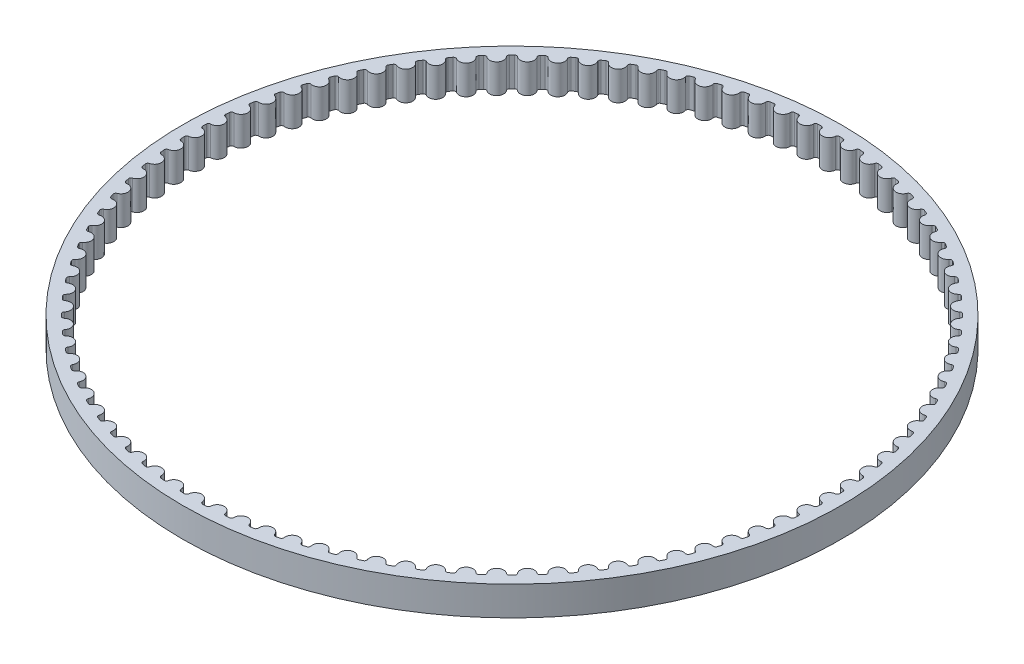
from build123d import *

# Parameters (mm, degrees)
SKETCH1_R           = 45.045764293
BOSS_EXTRUDE1_DEPTH = 4


with BuildPart() as part:
    # Sketch1 → Boss-Extrude1 (new body)
    with BuildSketch(Plane(origin=(0, 0, 0), x_dir=(1, 0, 0), z_dir=(0, 1, 0))):
        Circle(SKETCH1_R)
        with BuildLine():
            ThreePointArc((-1.725557121, -43.511562147), (-1.486700737, -43.520378087), (-1.247799561, -43.527882836))
            ThreePointArc((-1.247799561, -43.527882836), (-1.042007938, -43.453736054), (-0.941771649, -43.25931223))
            ThreePointArc((-0.941771649, -43.25931223), (0, -42.408617244), (0.941771649, -43.25931223))
            ThreePointArc((0.941771649, -43.25931223), (1.042007938, -43.453736054), (1.247799561, -43.527882836))
            ThreePointArc((1.247799561, -43.527882836), (1.486700737, -43.520378087), (1.725557121, -43.511562147))
            ThreePointArc((1.725557121, -43.511562147), (1.925809041, -43.423544502), (2.012543705, -43.222733559))
            ThreePointArc((2.012543705, -43.222733559), (2.894066388, -42.309752968), (3.891696029, -43.094196018))
            ThreePointArc((3.891696029, -43.094196018), (4.004966595, -43.281326229), (4.215338425, -43.341256441))
            ThreePointArc((4.215338425, -43.341256441), (4.453170525, -43.317465994), (4.69086846, -43.292370471))
            ThreePointArc((4.69086846, -43.292370471), (4.884647009, -43.190892341), (4.957475652, -42.984630551))
            ThreePointArc((4.957475652, -42.984630551), (5.774639303, -42.013621094), (6.823475525, -42.728154772))
            ThreePointArc((6.823475525, -42.728154772), (6.949252249, -42.907118882), (7.163223436, -42.952553101))
            ThreePointArc((7.163223436, -42.952553101), (7.398877577, -42.912587879), (7.634308804, -42.871329779))
            ThreePointArc((7.634308804, -42.871329779), (7.820710498, -42.756864302), (7.879293558, -42.546113353))
            ThreePointArc((7.879293558, -42.546113353), (8.628288183, -41.521602324), (9.723440829, -42.162895144))
            ThreePointArc((9.723440829, -42.162895144), (9.861137282, -42.33285874), (10.077710193, -42.363585131))
            ThreePointArc((10.077710193, -42.363585131), (10.310087647, -42.30763147), (10.542154476, -42.250403157))
            ThreePointArc((10.542154476, -42.250403157), (10.720310225, -42.123484024), (10.764374561, -41.909226535))
            ThreePointArc((10.764374561, -41.909226535), (11.441708002, -40.835990676), (12.578070964, -41.401052635))
            ThreePointArc((12.578070964, -41.401052635), (12.72704514, -41.561223269), (12.945210013, -41.577098571))
            ThreePointArc((12.945210013, -41.577098571), (13.173227328, -41.505417353), (13.400847758, -41.432485652))
            ThreePointArc((13.400847758, -41.432485652), (13.569926916, -41.293704618), (13.59926708, -41.076939557))
            ThreePointArc((13.59926708, -41.076939557), (14.201781295, -39.95998279), (15.374056325, -40.446179308))
            ThreePointArc((15.374056325, -40.446179308), (15.533613638, -40.59581019), (15.752353287, -40.596760386))
            ThreePointArc((15.752353287, -40.596760386), (15.974947342, -40.509685821), (16.197060101, -40.421390772))
            ThreePointArc((16.197060101, -40.421390772), (16.356274344, -40.2713949), (16.370753539, -40.053132924))
            ThreePointArc((16.370753539, -40.053132924), (16.895639329, -38.897663017), (18.098360738, -39.302727221))
            ThreePointArc((18.098360738, -39.302727221), (18.267757259, -39.441120703), (18.48605182, -39.427141362))
            ThreePointArc((18.48605182, -39.427141362), (18.702184778, -39.325079433), (18.917754273, -39.22183271))
            ThreePointArc((18.917754273, -39.22183271), (19.066361271, -39.061321348), (19.065911987, -38.842580096))
            ThreePointArc((19.065911987, -38.842580096), (19.510722092, -37.653984383), (20.738282239, -37.976027678))
            ThreePointArc((20.738282239, -37.976027678), (20.916728163, -38.102538505), (21.133559845, -38.073694806))
            ThreePointArc((21.133559845, -38.073694806), (21.342223995, -37.957121372), (21.550245143, -37.839404358))
            ThreePointArc((21.550245143, -37.839404358), (21.687552021, -37.669125885), (21.672176353, -37.45092523))
            ThreePointArc((21.672176353, -37.45092523), (22.034836863, -36.234745493), (23.281512296, -36.472266363))
            ThreePointArc((23.281512296, -36.472266363), (23.468175625, -36.586304684), (23.682533458, -36.542731109))
            ThreePointArc((23.682533458, -36.542731109), (23.882755912, -36.412189689), (24.082258821, -36.280551236))
            ThreePointArc((24.082258821, -36.280551236), (24.207625391, -36.101299569), (24.177395028, -35.884656862))
            ThreePointArc((24.177395028, -35.884656862), (24.456215052, -34.646563492), (25.716193194, -34.798454506))
            ThreePointArc((25.716193194, -34.798454506), (25.910203619, -34.899488621), (26.121088168, -34.84138833))
            ThreePointArc((26.121088168, -34.84138833), (26.311935396, -34.697487569), (26.501989892, -34.552541436))
            ThreePointArc((26.501989892, -34.552541436), (26.614831637, -34.365152328), (26.569887527, -34.151077659))
            ThreePointArc((26.569887527, -34.151077659), (26.763567078, -32.896843219), (28.030973329, -32.962396191))
            ThreePointArc((28.030973329, -32.962396191), (28.231426282, -33.049955033), (28.437854308, -32.977598916))
            ThreePointArc((28.437854308, -32.977598916), (28.618436491, -32.821009746), (28.798156452, -32.663431738))
            ThreePointArc((28.798156452, -32.663431738), (28.897947252, -32.468778884), (28.838498945, -32.258270367))
            ThreePointArc((28.838498945, -32.258270367), (28.946134999, -30.993742677), (30.215060127, -30.972651969))
            ThreePointArc((30.215060127, -30.972651969), (30.421021005, -31.046327297), (30.622030042, -30.960052713))
            ThreePointArc((30.622030042, -30.960052713), (30.791505224, -30.791505224), (30.960052713, -30.622030042))
            ThreePointArc((30.960052713, -30.622030042), (31.046327297, -30.421021005), (30.972651969, -30.215060127))
            ThreePointArc((30.972651969, -30.215060127), (30.993742677, -28.946134999), (32.258270367, -28.838498945))
            ThreePointArc((32.258270367, -28.838498945), (32.468778884, -28.897947252), (32.663431738, -28.798156452))
            ThreePointArc((32.663431738, -28.798156452), (32.821009746, -28.618436491), (32.977598916, -28.437854308))
            ThreePointArc((32.977598916, -28.437854308), (33.049955033, -28.231426282), (32.962396191, -28.030973329))
            ThreePointArc((32.962396191, -28.030973329), (32.896843219, -26.763567078), (34.151077659, -26.569887527))
            ThreePointArc((34.151077659, -26.569887527), (34.365152328, -26.614831637), (34.552541436, -26.501989892))
            ThreePointArc((34.552541436, -26.501989892), (34.697487569, -26.311935396), (34.84138833, -26.121088168))
            ThreePointArc((34.84138833, -26.121088168), (34.899488621, -25.910203619), (34.798454506, -25.716193194))
            ThreePointArc((34.798454506, -25.716193194), (34.646563492, -24.456215052), (35.884656862, -24.177395028))
            ThreePointArc((35.884656862, -24.177395028), (36.101299569, -24.207625391), (36.280551236, -24.082258821))
            ThreePointArc((36.280551236, -24.082258821), (36.412189689, -23.882755912), (36.542731109, -23.682533458))
            ThreePointArc((36.542731109, -23.682533458), (36.586304684, -23.468175625), (36.472266363, -23.281512296))
            ThreePointArc((36.472266363, -23.281512296), (36.234745493, -22.034836863), (37.45092523, -21.672176353))
            ThreePointArc((37.45092523, -21.672176353), (37.669125885, -21.687552021), (37.839404358, -21.550245143))
            ThreePointArc((37.839404358, -21.550245143), (37.957121372, -21.342223995), (38.073694806, -21.133559845))
            ThreePointArc((38.073694806, -21.133559845), (38.102538505, -20.916728163), (37.976027678, -20.738282239))
            ThreePointArc((37.976027678, -20.738282239), (37.653984383, -19.510722092), (38.842580096, -19.065911987))
            ThreePointArc((38.842580096, -19.065911987), (39.061321348, -19.066361271), (39.22183271, -18.917754273))
            ThreePointArc((39.22183271, -18.917754273), (39.325079433, -18.702184778), (39.427141362, -18.48605182))
            ThreePointArc((39.427141362, -18.48605182), (39.441120703, -18.267757259), (39.302727221, -18.098360738))
            ThreePointArc((39.302727221, -18.098360738), (38.897663017, -16.895639329), (40.053132924, -16.370753539))
            ThreePointArc((40.053132924, -16.370753539), (40.2713949, -16.356274344), (40.421390772, -16.197060101))
            ThreePointArc((40.421390772, -16.197060101), (40.509685821, -15.974947342), (40.596760386, -15.752353287))
            ThreePointArc((40.596760386, -15.752353287), (40.59581019, -15.533613638), (40.446179308, -15.374056325))
            ThreePointArc((40.446179308, -15.374056325), (39.95998279, -14.201781295), (41.076939557, -13.59926708))
            ThreePointArc((41.076939557, -13.59926708), (41.293704618, -13.569926916), (41.432485652, -13.400847758))
            ThreePointArc((41.432485652, -13.400847758), (41.505417353, -13.173227328), (41.577098571, -12.945210013))
            ThreePointArc((41.577098571, -12.945210013), (41.561223269, -12.72704514), (41.401052635, -12.578070964))
            ThreePointArc((41.401052635, -12.578070964), (40.835990676, -11.441708002), (41.909226535, -10.764374561))
            ThreePointArc((41.909226535, -10.764374561), (42.123484024, -10.720310225), (42.250403157, -10.542154476))
            ThreePointArc((42.250403157, -10.542154476), (42.30763147, -10.310087647), (42.363585131, -10.077710193))
            ThreePointArc((42.363585131, -10.077710193), (42.33285874, -9.861137282), (42.162895144, -9.723440829))
            ThreePointArc((42.162895144, -9.723440829), (41.521602324, -8.628288183), (42.546113353, -7.879293558))
            ThreePointArc((42.546113353, -7.879293558), (42.756864302, -7.820710498), (42.871329779, -7.634308804))
            ThreePointArc((42.871329779, -7.634308804), (42.912587879, -7.398877577), (42.952553101, -7.163223436))
            ThreePointArc((42.952553101, -7.163223436), (42.907118882, -6.949252249), (42.728154772, -6.823475525))
            ThreePointArc((42.728154772, -6.823475525), (42.013621094, -5.774639303), (42.984630551, -4.957475652))
            ThreePointArc((42.984630551, -4.957475652), (43.190892341, -4.884647009), (43.292370471, -4.69086846))
            ThreePointArc((43.292370471, -4.69086846), (43.317465994, -4.453170525), (43.341256441, -4.215338425))
            ThreePointArc((43.341256441, -4.215338425), (43.281326229, -4.004966595), (43.094196018, -3.891696029))
            ThreePointArc((43.094196018, -3.891696029), (42.309752968, -2.894066388), (43.222733559, -2.012543705))
            ThreePointArc((43.222733559, -2.012543705), (43.423544502, -1.925809041), (43.511562147, -1.725557121))
            ThreePointArc((43.511562147, -1.725557121), (43.520378087, -1.486700737), (43.527882836, -1.247799561))
            ThreePointArc((43.527882836, -1.247799561), (43.453736054, -1.042007938), (43.25931223, -0.941771649))
            ThreePointArc((43.25931223, -0.941771649), (42.408617244, 0), (43.25931223, 0.941771649))
            ThreePointArc((43.25931223, 0.941771649), (43.453736054, 1.042007938), (43.527882836, 1.247799561))
            ThreePointArc((43.527882836, 1.247799561), (43.520378087, 1.486700737), (43.511562147, 1.725557121))
            ThreePointArc((43.511562147, 1.725557121), (43.423544502, 1.925809041), (43.222733559, 2.012543705))
            ThreePointArc((43.222733559, 2.012543705), (42.309752968, 2.894066388), (43.094196018, 3.891696029))
            ThreePointArc((43.094196018, 3.891696029), (43.281326229, 4.004966595), (43.341256441, 4.215338425))
            ThreePointArc((43.341256441, 4.215338425), (43.317465994, 4.453170525), (43.292370471, 4.69086846))
            ThreePointArc((43.292370471, 4.69086846), (43.190892341, 4.884647009), (42.984630551, 4.957475652))
            ThreePointArc((42.984630551, 4.957475652), (42.013621094, 5.774639303), (42.728154772, 6.823475525))
            ThreePointArc((42.728154772, 6.823475525), (42.907118882, 6.949252249), (42.952553101, 7.163223436))
            ThreePointArc((42.952553101, 7.163223436), (42.912587879, 7.398877577), (42.871329779, 7.634308804))
            ThreePointArc((42.871329779, 7.634308804), (42.756864302, 7.820710498), (42.546113353, 7.879293558))
            ThreePointArc((42.546113353, 7.879293558), (41.521602324, 8.628288183), (42.162895144, 9.723440829))
            ThreePointArc((42.162895144, 9.723440829), (42.33285874, 9.861137282), (42.363585131, 10.077710193))
            ThreePointArc((42.363585131, 10.077710193), (42.30763147, 10.310087647), (42.250403157, 10.542154476))
            ThreePointArc((42.250403157, 10.542154476), (42.123484024, 10.720310225), (41.909226535, 10.764374561))
            ThreePointArc((41.909226535, 10.764374561), (40.835990676, 11.441708002), (41.401052635, 12.578070964))
            ThreePointArc((41.401052635, 12.578070964), (41.561223269, 12.72704514), (41.577098571, 12.945210013))
            ThreePointArc((41.577098571, 12.945210013), (41.505417353, 13.173227328), (41.432485652, 13.400847758))
            ThreePointArc((41.432485652, 13.400847758), (41.293704618, 13.569926916), (41.076939557, 13.59926708))
            ThreePointArc((41.076939557, 13.59926708), (39.95998279, 14.201781295), (40.446179308, 15.374056325))
            ThreePointArc((40.446179308, 15.374056325), (40.59581019, 15.533613638), (40.596760386, 15.752353287))
            ThreePointArc((40.596760386, 15.752353287), (40.509685821, 15.974947342), (40.421390772, 16.197060101))
            ThreePointArc((40.421390772, 16.197060101), (40.2713949, 16.356274344), (40.053132924, 16.370753539))
            ThreePointArc((40.053132924, 16.370753539), (38.897663017, 16.895639329), (39.302727221, 18.098360738))
            ThreePointArc((39.302727221, 18.098360738), (39.441120703, 18.267757259), (39.427141362, 18.48605182))
            ThreePointArc((39.427141362, 18.48605182), (39.325079433, 18.702184778), (39.22183271, 18.917754273))
            ThreePointArc((39.22183271, 18.917754273), (39.061321348, 19.066361271), (38.842580096, 19.065911987))
            ThreePointArc((38.842580096, 19.065911987), (37.653984383, 19.510722092), (37.976027678, 20.738282239))
            ThreePointArc((37.976027678, 20.738282239), (38.102538505, 20.916728163), (38.073694806, 21.133559845))
            ThreePointArc((38.073694806, 21.133559845), (37.957121372, 21.342223995), (37.839404358, 21.550245143))
            ThreePointArc((37.839404358, 21.550245143), (37.669125885, 21.687552021), (37.45092523, 21.672176353))
            ThreePointArc((37.45092523, 21.672176353), (36.234745493, 22.034836863), (36.472266363, 23.281512296))
            ThreePointArc((36.472266363, 23.281512296), (36.586304684, 23.468175625), (36.542731109, 23.682533458))
            ThreePointArc((36.542731109, 23.682533458), (36.412189689, 23.882755912), (36.280551236, 24.082258821))
            ThreePointArc((36.280551236, 24.082258821), (36.101299569, 24.207625391), (35.884656862, 24.177395028))
            ThreePointArc((35.884656862, 24.177395028), (34.646563492, 24.456215052), (34.798454506, 25.716193194))
            ThreePointArc((34.798454506, 25.716193194), (34.899488621, 25.910203619), (34.84138833, 26.121088168))
            ThreePointArc((34.84138833, 26.121088168), (34.697487569, 26.311935396), (34.552541436, 26.501989892))
            ThreePointArc((34.552541436, 26.501989892), (34.365152328, 26.614831637), (34.151077659, 26.569887527))
            ThreePointArc((34.151077659, 26.569887527), (32.896843219, 26.763567078), (32.962396191, 28.030973329))
            ThreePointArc((32.962396191, 28.030973329), (33.049955033, 28.231426282), (32.977598916, 28.437854308))
            ThreePointArc((32.977598916, 28.437854308), (32.821009746, 28.618436491), (32.663431738, 28.798156452))
            ThreePointArc((32.663431738, 28.798156452), (32.468778884, 28.897947252), (32.258270367, 28.838498945))
            ThreePointArc((32.258270367, 28.838498945), (30.993742677, 28.946134999), (30.972651969, 30.215060127))
            ThreePointArc((30.972651969, 30.215060127), (31.046327297, 30.421021005), (30.960052713, 30.622030042))
            ThreePointArc((30.960052713, 30.622030042), (30.791505224, 30.791505224), (30.622030042, 30.960052713))
            ThreePointArc((30.622030042, 30.960052713), (30.421021005, 31.046327297), (30.215060127, 30.972651969))
            ThreePointArc((30.215060127, 30.972651969), (28.946134999, 30.993742677), (28.838498945, 32.258270367))
            ThreePointArc((28.838498945, 32.258270367), (28.897947252, 32.468778884), (28.798156452, 32.663431738))
            ThreePointArc((28.798156452, 32.663431738), (28.618436491, 32.821009746), (28.437854308, 32.977598916))
            ThreePointArc((28.437854308, 32.977598916), (28.231426282, 33.049955033), (28.030973329, 32.962396191))
            ThreePointArc((28.030973329, 32.962396191), (26.763567078, 32.896843219), (26.569887527, 34.151077659))
            ThreePointArc((26.569887527, 34.151077659), (26.614831637, 34.365152328), (26.501989892, 34.552541436))
            ThreePointArc((26.501989892, 34.552541436), (26.311935396, 34.697487569), (26.121088168, 34.84138833))
            ThreePointArc((26.121088168, 34.84138833), (25.910203619, 34.899488621), (25.716193194, 34.798454506))
            ThreePointArc((25.716193194, 34.798454506), (24.456215052, 34.646563492), (24.177395028, 35.884656862))
            ThreePointArc((24.177395028, 35.884656862), (24.207625391, 36.101299569), (24.082258821, 36.280551236))
            ThreePointArc((24.082258821, 36.280551236), (23.882755912, 36.412189689), (23.682533458, 36.542731109))
            ThreePointArc((23.682533458, 36.542731109), (23.468175625, 36.586304684), (23.281512296, 36.472266363))
            ThreePointArc((23.281512296, 36.472266363), (22.034836863, 36.234745493), (21.672176353, 37.45092523))
            ThreePointArc((21.672176353, 37.45092523), (21.687552021, 37.669125885), (21.550245143, 37.839404358))
            ThreePointArc((21.550245143, 37.839404358), (21.342223995, 37.957121372), (21.133559845, 38.073694806))
            ThreePointArc((21.133559845, 38.073694806), (20.916728163, 38.102538505), (20.738282239, 37.976027678))
            ThreePointArc((20.738282239, 37.976027678), (19.510722092, 37.653984383), (19.065911987, 38.842580096))
            ThreePointArc((19.065911987, 38.842580096), (19.066361271, 39.061321348), (18.917754273, 39.22183271))
            ThreePointArc((18.917754273, 39.22183271), (18.702184778, 39.325079433), (18.48605182, 39.427141362))
            ThreePointArc((18.48605182, 39.427141362), (18.267757259, 39.441120703), (18.098360738, 39.302727221))
            ThreePointArc((18.098360738, 39.302727221), (16.895639329, 38.897663017), (16.370753539, 40.053132924))
            ThreePointArc((16.370753539, 40.053132924), (16.356274344, 40.2713949), (16.197060101, 40.421390772))
            ThreePointArc((16.197060101, 40.421390772), (15.974947342, 40.509685821), (15.752353287, 40.596760386))
            ThreePointArc((15.752353287, 40.596760386), (15.533613638, 40.59581019), (15.374056325, 40.446179308))
            ThreePointArc((15.374056325, 40.446179308), (14.201781295, 39.95998279), (13.59926708, 41.076939557))
            ThreePointArc((13.59926708, 41.076939557), (13.569926916, 41.293704618), (13.400847758, 41.432485652))
            ThreePointArc((13.400847758, 41.432485652), (13.173227328, 41.505417353), (12.945210013, 41.577098571))
            ThreePointArc((12.945210013, 41.577098571), (12.72704514, 41.561223269), (12.578070964, 41.401052635))
            ThreePointArc((12.578070964, 41.401052635), (11.441708002, 40.835990676), (10.764374561, 41.909226535))
            ThreePointArc((10.764374561, 41.909226535), (10.720310225, 42.123484024), (10.542154476, 42.250403157))
            ThreePointArc((10.542154476, 42.250403157), (10.310087647, 42.30763147), (10.077710193, 42.363585131))
            ThreePointArc((10.077710193, 42.363585131), (9.861137282, 42.33285874), (9.723440829, 42.162895144))
            ThreePointArc((9.723440829, 42.162895144), (8.628288183, 41.521602324), (7.879293558, 42.546113353))
            ThreePointArc((7.879293558, 42.546113353), (7.820710498, 42.756864302), (7.634308804, 42.871329779))
            ThreePointArc((7.634308804, 42.871329779), (7.398877577, 42.912587879), (7.163223436, 42.952553101))
            ThreePointArc((7.163223436, 42.952553101), (6.949252249, 42.907118882), (6.823475525, 42.728154772))
            ThreePointArc((6.823475525, 42.728154772), (5.774639303, 42.013621094), (4.957475652, 42.984630551))
            ThreePointArc((4.957475652, 42.984630551), (4.884647009, 43.190892341), (4.69086846, 43.292370471))
            ThreePointArc((4.69086846, 43.292370471), (4.453170525, 43.317465994), (4.215338425, 43.341256441))
            ThreePointArc((4.215338425, 43.341256441), (4.004966595, 43.281326229), (3.891696029, 43.094196018))
            ThreePointArc((3.891696029, 43.094196018), (2.894066388, 42.309752968), (2.012543705, 43.222733559))
            ThreePointArc((2.012543705, 43.222733559), (1.925809041, 43.423544502), (1.725557121, 43.511562147))
            ThreePointArc((1.725557121, 43.511562147), (1.486700737, 43.520378087), (1.247799561, 43.527882836))
            ThreePointArc((1.247799561, 43.527882836), (1.042007938, 43.453736054), (0.941771649, 43.25931223))
            ThreePointArc((0.941771649, 43.25931223), (0, 42.408617244), (-0.941771649, 43.25931223))
            ThreePointArc((-0.941771649, 43.25931223), (-1.042007938, 43.453736054), (-1.247799561, 43.527882836))
            ThreePointArc((-1.247799561, 43.527882836), (-1.486700737, 43.520378087), (-1.725557121, 43.511562147))
            ThreePointArc((-1.725557121, 43.511562147), (-1.925809041, 43.423544502), (-2.012543705, 43.222733559))
            ThreePointArc((-2.012543705, 43.222733559), (-2.894066388, 42.309752968), (-3.891696029, 43.094196018))
            ThreePointArc((-3.891696029, 43.094196018), (-4.004966595, 43.281326229), (-4.215338425, 43.341256441))
            ThreePointArc((-4.215338425, 43.341256441), (-4.453170525, 43.317465994), (-4.69086846, 43.292370471))
            ThreePointArc((-4.69086846, 43.292370471), (-4.884647009, 43.190892341), (-4.957475652, 42.984630551))
            ThreePointArc((-4.957475652, 42.984630551), (-5.774639303, 42.013621094), (-6.823475525, 42.728154772))
            ThreePointArc((-6.823475525, 42.728154772), (-6.949252249, 42.907118882), (-7.163223436, 42.952553101))
            ThreePointArc((-7.163223436, 42.952553101), (-7.398877577, 42.912587879), (-7.634308804, 42.871329779))
            ThreePointArc((-7.634308804, 42.871329779), (-7.820710498, 42.756864302), (-7.879293558, 42.546113353))
            ThreePointArc((-7.879293558, 42.546113353), (-8.628288183, 41.521602324), (-9.723440829, 42.162895144))
            ThreePointArc((-9.723440829, 42.162895144), (-9.861137282, 42.33285874), (-10.077710193, 42.363585131))
            ThreePointArc((-10.077710193, 42.363585131), (-10.310087647, 42.30763147), (-10.542154476, 42.250403157))
            ThreePointArc((-10.542154476, 42.250403157), (-10.720310225, 42.123484024), (-10.764374561, 41.909226535))
            ThreePointArc((-10.764374561, 41.909226535), (-11.441708002, 40.835990676), (-12.578070964, 41.401052635))
            ThreePointArc((-12.578070964, 41.401052635), (-12.72704514, 41.561223269), (-12.945210013, 41.577098571))
            ThreePointArc((-12.945210013, 41.577098571), (-13.173227328, 41.505417353), (-13.400847758, 41.432485652))
            ThreePointArc((-13.400847758, 41.432485652), (-13.569926916, 41.293704618), (-13.59926708, 41.076939557))
            ThreePointArc((-13.59926708, 41.076939557), (-14.201781295, 39.95998279), (-15.374056325, 40.446179308))
            ThreePointArc((-15.374056325, 40.446179308), (-15.533613638, 40.59581019), (-15.752353287, 40.596760386))
            ThreePointArc((-15.752353287, 40.596760386), (-15.974947342, 40.509685821), (-16.197060101, 40.421390772))
            ThreePointArc((-16.197060101, 40.421390772), (-16.356274344, 40.2713949), (-16.370753539, 40.053132924))
            ThreePointArc((-16.370753539, 40.053132924), (-16.895639329, 38.897663017), (-18.098360738, 39.302727221))
            ThreePointArc((-18.098360738, 39.302727221), (-18.267757259, 39.441120703), (-18.48605182, 39.427141362))
            ThreePointArc((-18.48605182, 39.427141362), (-18.702184778, 39.325079433), (-18.917754273, 39.22183271))
            ThreePointArc((-18.917754273, 39.22183271), (-19.066361271, 39.061321348), (-19.065911987, 38.842580096))
            ThreePointArc((-19.065911987, 38.842580096), (-19.510722092, 37.653984383), (-20.738282239, 37.976027678))
            ThreePointArc((-20.738282239, 37.976027678), (-20.916728163, 38.102538505), (-21.133559845, 38.073694806))
            ThreePointArc((-21.133559845, 38.073694806), (-21.342223995, 37.957121372), (-21.550245143, 37.839404358))
            ThreePointArc((-21.550245143, 37.839404358), (-21.687552021, 37.669125885), (-21.672176353, 37.45092523))
            ThreePointArc((-21.672176353, 37.45092523), (-22.034836863, 36.234745493), (-23.281512296, 36.472266363))
            ThreePointArc((-23.281512296, 36.472266363), (-23.468175625, 36.586304684), (-23.682533458, 36.542731109))
            ThreePointArc((-23.682533458, 36.542731109), (-23.882755912, 36.412189689), (-24.082258821, 36.280551236))
            ThreePointArc((-24.082258821, 36.280551236), (-24.207625391, 36.101299569), (-24.177395028, 35.884656862))
            ThreePointArc((-24.177395028, 35.884656862), (-24.456215052, 34.646563492), (-25.716193194, 34.798454506))
            ThreePointArc((-25.716193194, 34.798454506), (-25.910203619, 34.899488621), (-26.121088168, 34.84138833))
            ThreePointArc((-26.121088168, 34.84138833), (-26.311935396, 34.697487569), (-26.501989892, 34.552541436))
            ThreePointArc((-26.501989892, 34.552541436), (-26.614831637, 34.365152328), (-26.569887527, 34.151077659))
            ThreePointArc((-26.569887527, 34.151077659), (-26.763567078, 32.896843219), (-28.030973329, 32.962396191))
            ThreePointArc((-28.030973329, 32.962396191), (-28.231426282, 33.049955033), (-28.437854308, 32.977598916))
            ThreePointArc((-28.437854308, 32.977598916), (-28.618436491, 32.821009746), (-28.798156452, 32.663431738))
            ThreePointArc((-28.798156452, 32.663431738), (-28.897947252, 32.468778884), (-28.838498945, 32.258270367))
            ThreePointArc((-28.838498945, 32.258270367), (-28.946134999, 30.993742677), (-30.215060127, 30.972651969))
            ThreePointArc((-30.215060127, 30.972651969), (-30.421021005, 31.046327297), (-30.622030042, 30.960052713))
            ThreePointArc((-30.622030042, 30.960052713), (-30.791505224, 30.791505224), (-30.960052713, 30.622030042))
            ThreePointArc((-30.960052713, 30.622030042), (-31.046327297, 30.421021005), (-30.972651969, 30.215060127))
            ThreePointArc((-30.972651969, 30.215060127), (-30.993742677, 28.946134999), (-32.258270367, 28.838498945))
            ThreePointArc((-32.258270367, 28.838498945), (-32.468778884, 28.897947252), (-32.663431738, 28.798156452))
            ThreePointArc((-32.663431738, 28.798156452), (-32.821009746, 28.618436491), (-32.977598916, 28.437854308))
            ThreePointArc((-32.977598916, 28.437854308), (-33.049955033, 28.231426282), (-32.962396191, 28.030973329))
            ThreePointArc((-32.962396191, 28.030973329), (-32.896843219, 26.763567078), (-34.151077659, 26.569887527))
            ThreePointArc((-34.151077659, 26.569887527), (-34.365152328, 26.614831637), (-34.552541436, 26.501989892))
            ThreePointArc((-34.552541436, 26.501989892), (-34.697487569, 26.311935396), (-34.84138833, 26.121088168))
            ThreePointArc((-34.84138833, 26.121088168), (-34.899488621, 25.910203619), (-34.798454506, 25.716193194))
            ThreePointArc((-34.798454506, 25.716193194), (-34.646563492, 24.456215052), (-35.884656862, 24.177395028))
            ThreePointArc((-35.884656862, 24.177395028), (-36.101299569, 24.207625391), (-36.280551236, 24.082258821))
            ThreePointArc((-36.280551236, 24.082258821), (-36.412189689, 23.882755912), (-36.542731109, 23.682533458))
            ThreePointArc((-36.542731109, 23.682533458), (-36.586304684, 23.468175625), (-36.472266363, 23.281512296))
            ThreePointArc((-36.472266363, 23.281512296), (-36.234745493, 22.034836863), (-37.45092523, 21.672176353))
            ThreePointArc((-37.45092523, 21.672176353), (-37.669125885, 21.687552021), (-37.839404358, 21.550245143))
            ThreePointArc((-37.839404358, 21.550245143), (-37.957121372, 21.342223995), (-38.073694806, 21.133559845))
            ThreePointArc((-38.073694806, 21.133559845), (-38.102538505, 20.916728163), (-37.976027678, 20.738282239))
            ThreePointArc((-37.976027678, 20.738282239), (-37.653984383, 19.510722092), (-38.842580096, 19.065911987))
            ThreePointArc((-38.842580096, 19.065911987), (-39.061321348, 19.066361271), (-39.22183271, 18.917754273))
            ThreePointArc((-39.22183271, 18.917754273), (-39.325079433, 18.702184778), (-39.427141362, 18.48605182))
            ThreePointArc((-39.427141362, 18.48605182), (-39.441120703, 18.267757259), (-39.302727221, 18.098360738))
            ThreePointArc((-39.302727221, 18.098360738), (-38.897663017, 16.895639329), (-40.053132924, 16.370753539))
            ThreePointArc((-40.053132924, 16.370753539), (-40.2713949, 16.356274344), (-40.421390772, 16.197060101))
            ThreePointArc((-40.421390772, 16.197060101), (-40.509685821, 15.974947342), (-40.596760386, 15.752353287))
            ThreePointArc((-40.596760386, 15.752353287), (-40.59581019, 15.533613638), (-40.446179308, 15.374056325))
            ThreePointArc((-40.446179308, 15.374056325), (-39.95998279, 14.201781295), (-41.076939557, 13.59926708))
            ThreePointArc((-41.076939557, 13.59926708), (-41.293704618, 13.569926916), (-41.432485652, 13.400847758))
            ThreePointArc((-41.432485652, 13.400847758), (-41.505417353, 13.173227328), (-41.577098571, 12.945210013))
            ThreePointArc((-41.577098571, 12.945210013), (-41.561223269, 12.72704514), (-41.401052635, 12.578070964))
            ThreePointArc((-41.401052635, 12.578070964), (-40.835990676, 11.441708002), (-41.909226535, 10.764374561))
            ThreePointArc((-41.909226535, 10.764374561), (-42.123484024, 10.720310225), (-42.250403157, 10.542154476))
            ThreePointArc((-42.250403157, 10.542154476), (-42.30763147, 10.310087647), (-42.363585131, 10.077710193))
            ThreePointArc((-42.363585131, 10.077710193), (-42.33285874, 9.861137282), (-42.162895144, 9.723440829))
            ThreePointArc((-42.162895144, 9.723440829), (-41.521602324, 8.628288183), (-42.546113353, 7.879293558))
            ThreePointArc((-42.546113353, 7.879293558), (-42.756864302, 7.820710498), (-42.871329779, 7.634308804))
            ThreePointArc((-42.871329779, 7.634308804), (-42.912587879, 7.398877577), (-42.952553101, 7.163223436))
            ThreePointArc((-42.952553101, 7.163223436), (-42.907118882, 6.949252249), (-42.728154772, 6.823475525))
            ThreePointArc((-42.728154772, 6.823475525), (-42.013621094, 5.774639303), (-42.984630551, 4.957475652))
            ThreePointArc((-42.984630551, 4.957475652), (-43.190892341, 4.884647009), (-43.292370471, 4.69086846))
            ThreePointArc((-43.292370471, 4.69086846), (-43.317465994, 4.453170525), (-43.341256441, 4.215338425))
            ThreePointArc((-43.341256441, 4.215338425), (-43.281326229, 4.004966595), (-43.094196018, 3.891696029))
            ThreePointArc((-43.094196018, 3.891696029), (-42.309752968, 2.894066388), (-43.222733559, 2.012543705))
            ThreePointArc((-43.222733559, 2.012543705), (-43.423544502, 1.925809041), (-43.511562147, 1.725557121))
            ThreePointArc((-43.511562147, 1.725557121), (-43.520378087, 1.486700737), (-43.527882836, 1.247799561))
            ThreePointArc((-43.527882836, 1.247799561), (-43.453736054, 1.042007938), (-43.25931223, 0.941771649))
            ThreePointArc((-43.25931223, 0.941771649), (-42.408617244, 0), (-43.25931223, -0.941771649))
            ThreePointArc((-43.25931223, -0.941771649), (-43.453736054, -1.042007938), (-43.527882836, -1.247799561))
            ThreePointArc((-43.527882836, -1.247799561), (-43.520378087, -1.486700737), (-43.511562147, -1.725557121))
            ThreePointArc((-43.511562147, -1.725557121), (-43.423544502, -1.925809041), (-43.222733559, -2.012543705))
            ThreePointArc((-43.222733559, -2.012543705), (-42.309752968, -2.894066388), (-43.094196018, -3.891696029))
            ThreePointArc((-43.094196018, -3.891696029), (-43.281326229, -4.004966595), (-43.341256441, -4.215338425))
            ThreePointArc((-43.341256441, -4.215338425), (-43.317465994, -4.453170525), (-43.292370471, -4.69086846))
            ThreePointArc((-43.292370471, -4.69086846), (-43.190892341, -4.884647009), (-42.984630551, -4.957475652))
            ThreePointArc((-42.984630551, -4.957475652), (-42.013621094, -5.774639303), (-42.728154772, -6.823475525))
            ThreePointArc((-42.728154772, -6.823475525), (-42.907118882, -6.949252249), (-42.952553101, -7.163223436))
            ThreePointArc((-42.952553101, -7.163223436), (-42.912587879, -7.398877577), (-42.871329779, -7.634308804))
            ThreePointArc((-42.871329779, -7.634308804), (-42.756864302, -7.820710498), (-42.546113353, -7.879293558))
            ThreePointArc((-42.546113353, -7.879293558), (-41.521602324, -8.628288183), (-42.162895144, -9.723440829))
            ThreePointArc((-42.162895144, -9.723440829), (-42.33285874, -9.861137282), (-42.363585131, -10.077710193))
            ThreePointArc((-42.363585131, -10.077710193), (-42.30763147, -10.310087647), (-42.250403157, -10.542154476))
            ThreePointArc((-42.250403157, -10.542154476), (-42.123484024, -10.720310225), (-41.909226535, -10.764374561))
            ThreePointArc((-41.909226535, -10.764374561), (-40.835990676, -11.441708002), (-41.401052635, -12.578070964))
            ThreePointArc((-41.401052635, -12.578070964), (-41.561223269, -12.72704514), (-41.577098571, -12.945210013))
            ThreePointArc((-41.577098571, -12.945210013), (-41.505417353, -13.173227328), (-41.432485652, -13.400847758))
            ThreePointArc((-41.432485652, -13.400847758), (-41.293704618, -13.569926916), (-41.076939557, -13.59926708))
            ThreePointArc((-41.076939557, -13.59926708), (-39.95998279, -14.201781295), (-40.446179308, -15.374056325))
            ThreePointArc((-40.446179308, -15.374056325), (-40.59581019, -15.533613638), (-40.596760386, -15.752353287))
            ThreePointArc((-40.596760386, -15.752353287), (-40.509685821, -15.974947342), (-40.421390772, -16.197060101))
            ThreePointArc((-40.421390772, -16.197060101), (-40.2713949, -16.356274344), (-40.053132924, -16.370753539))
            ThreePointArc((-40.053132924, -16.370753539), (-38.897663017, -16.895639329), (-39.302727221, -18.098360738))
            ThreePointArc((-39.302727221, -18.098360738), (-39.441120703, -18.267757259), (-39.427141362, -18.48605182))
            ThreePointArc((-39.427141362, -18.48605182), (-39.325079433, -18.702184778), (-39.22183271, -18.917754273))
            ThreePointArc((-39.22183271, -18.917754273), (-39.061321348, -19.066361271), (-38.842580096, -19.065911987))
            ThreePointArc((-38.842580096, -19.065911987), (-37.653984383, -19.510722092), (-37.976027678, -20.738282239))
            ThreePointArc((-37.976027678, -20.738282239), (-38.102538505, -20.916728163), (-38.073694806, -21.133559845))
            ThreePointArc((-38.073694806, -21.133559845), (-37.957121372, -21.342223995), (-37.839404358, -21.550245143))
            ThreePointArc((-37.839404358, -21.550245143), (-37.669125885, -21.687552021), (-37.45092523, -21.672176353))
            ThreePointArc((-37.45092523, -21.672176353), (-36.234745493, -22.034836863), (-36.472266363, -23.281512296))
            ThreePointArc((-36.472266363, -23.281512296), (-36.586304684, -23.468175625), (-36.542731109, -23.682533458))
            ThreePointArc((-36.542731109, -23.682533458), (-36.412189689, -23.882755912), (-36.280551236, -24.082258821))
            ThreePointArc((-36.280551236, -24.082258821), (-36.101299569, -24.207625391), (-35.884656862, -24.177395028))
            ThreePointArc((-35.884656862, -24.177395028), (-34.646563492, -24.456215052), (-34.798454506, -25.716193194))
            ThreePointArc((-34.798454506, -25.716193194), (-34.899488621, -25.910203619), (-34.84138833, -26.121088168))
            ThreePointArc((-34.84138833, -26.121088168), (-34.697487569, -26.311935396), (-34.552541436, -26.501989892))
            ThreePointArc((-34.552541436, -26.501989892), (-34.365152328, -26.614831637), (-34.151077659, -26.569887527))
            ThreePointArc((-34.151077659, -26.569887527), (-32.896843219, -26.763567078), (-32.962396191, -28.030973329))
            ThreePointArc((-32.962396191, -28.030973329), (-33.049955033, -28.231426282), (-32.977598916, -28.437854308))
            ThreePointArc((-32.977598916, -28.437854308), (-32.821009746, -28.618436491), (-32.663431738, -28.798156452))
            ThreePointArc((-32.663431738, -28.798156452), (-32.468778884, -28.897947252), (-32.258270367, -28.838498945))
            ThreePointArc((-32.258270367, -28.838498945), (-30.993742677, -28.946134999), (-30.972651969, -30.215060127))
            ThreePointArc((-30.972651969, -30.215060127), (-31.046327297, -30.421021005), (-30.960052713, -30.622030042))
            ThreePointArc((-30.960052713, -30.622030042), (-30.791505224, -30.791505224), (-30.622030042, -30.960052713))
            ThreePointArc((-30.622030042, -30.960052713), (-30.421021005, -31.046327297), (-30.215060127, -30.972651969))
            ThreePointArc((-30.215060127, -30.972651969), (-28.946134999, -30.993742677), (-28.838498945, -32.258270367))
            ThreePointArc((-28.838498945, -32.258270367), (-28.897947252, -32.468778884), (-28.798156452, -32.663431738))
            ThreePointArc((-28.798156452, -32.663431738), (-28.618436491, -32.821009746), (-28.437854308, -32.977598916))
            ThreePointArc((-28.437854308, -32.977598916), (-28.231426282, -33.049955033), (-28.030973329, -32.962396191))
            ThreePointArc((-28.030973329, -32.962396191), (-26.763567078, -32.896843219), (-26.569887527, -34.151077659))
            ThreePointArc((-26.569887527, -34.151077659), (-26.614831637, -34.365152328), (-26.501989892, -34.552541436))
            ThreePointArc((-26.501989892, -34.552541436), (-26.311935396, -34.697487569), (-26.121088168, -34.84138833))
            ThreePointArc((-26.121088168, -34.84138833), (-25.910203619, -34.899488621), (-25.716193194, -34.798454506))
            ThreePointArc((-25.716193194, -34.798454506), (-24.456215052, -34.646563492), (-24.177395028, -35.884656862))
            ThreePointArc((-24.177395028, -35.884656862), (-24.207625391, -36.101299569), (-24.082258821, -36.280551236))
            ThreePointArc((-24.082258821, -36.280551236), (-23.882755912, -36.412189689), (-23.682533458, -36.542731109))
            ThreePointArc((-23.682533458, -36.542731109), (-23.468175625, -36.586304684), (-23.281512296, -36.472266363))
            ThreePointArc((-23.281512296, -36.472266363), (-22.034836863, -36.234745493), (-21.672176353, -37.45092523))
            ThreePointArc((-21.672176353, -37.45092523), (-21.687552021, -37.669125885), (-21.550245143, -37.839404358))
            ThreePointArc((-21.550245143, -37.839404358), (-21.342223995, -37.957121372), (-21.133559845, -38.073694806))
            ThreePointArc((-21.133559845, -38.073694806), (-20.916728163, -38.102538505), (-20.738282239, -37.976027678))
            ThreePointArc((-20.738282239, -37.976027678), (-19.510722092, -37.653984383), (-19.065911987, -38.842580096))
            ThreePointArc((-19.065911987, -38.842580096), (-19.066361271, -39.061321348), (-18.917754273, -39.22183271))
            ThreePointArc((-18.917754273, -39.22183271), (-18.702184778, -39.325079433), (-18.48605182, -39.427141362))
            ThreePointArc((-18.48605182, -39.427141362), (-18.267757259, -39.441120703), (-18.098360738, -39.302727221))
            ThreePointArc((-18.098360738, -39.302727221), (-16.895639329, -38.897663017), (-16.370753539, -40.053132924))
            ThreePointArc((-16.370753539, -40.053132924), (-16.356274344, -40.2713949), (-16.197060101, -40.421390772))
            ThreePointArc((-16.197060101, -40.421390772), (-15.974947342, -40.509685821), (-15.752353287, -40.596760386))
            ThreePointArc((-15.752353287, -40.596760386), (-15.533613638, -40.59581019), (-15.374056325, -40.446179308))
            ThreePointArc((-15.374056325, -40.446179308), (-14.201781295, -39.95998279), (-13.59926708, -41.076939557))
            ThreePointArc((-13.59926708, -41.076939557), (-13.569926916, -41.293704618), (-13.400847758, -41.432485652))
            ThreePointArc((-13.400847758, -41.432485652), (-13.173227328, -41.505417353), (-12.945210013, -41.577098571))
            ThreePointArc((-12.945210013, -41.577098571), (-12.72704514, -41.561223269), (-12.578070964, -41.401052635))
            ThreePointArc((-12.578070964, -41.401052635), (-11.441708002, -40.835990676), (-10.764374561, -41.909226535))
            ThreePointArc((-10.764374561, -41.909226535), (-10.720310225, -42.123484024), (-10.542154476, -42.250403157))
            ThreePointArc((-10.542154476, -42.250403157), (-10.310087647, -42.30763147), (-10.077710193, -42.363585131))
            ThreePointArc((-10.077710193, -42.363585131), (-9.861137282, -42.33285874), (-9.723440829, -42.162895144))
            ThreePointArc((-9.723440829, -42.162895144), (-8.628288183, -41.521602324), (-7.879293558, -42.546113353))
            ThreePointArc((-7.879293558, -42.546113353), (-7.820710498, -42.756864302), (-7.634308804, -42.871329779))
            ThreePointArc((-7.634308804, -42.871329779), (-7.398877577, -42.912587879), (-7.163223436, -42.952553101))
            ThreePointArc((-7.163223436, -42.952553101), (-6.949252249, -42.907118882), (-6.823475525, -42.728154772))
            ThreePointArc((-6.823475525, -42.728154772), (-5.774639303, -42.013621094), (-4.957475652, -42.984630551))
            ThreePointArc((-4.957475652, -42.984630551), (-4.884647009, -43.190892341), (-4.69086846, -43.292370471))
            ThreePointArc((-4.69086846, -43.292370471), (-4.453170525, -43.317465994), (-4.215338425, -43.341256441))
            ThreePointArc((-4.215338425, -43.341256441), (-4.004966595, -43.281326229), (-3.891696029, -43.094196018))
            ThreePointArc((-3.891696029, -43.094196018), (-2.894066388, -42.309752968), (-2.012543705, -43.222733559))
            ThreePointArc((-2.012543705, -43.222733559), (-1.925809041, -43.423544502), (-1.725557121, -43.511562147))
        make_face(mode=Mode.SUBTRACT)
    extrude(amount=BOSS_EXTRUDE1_DEPTH)


solid = part.part
